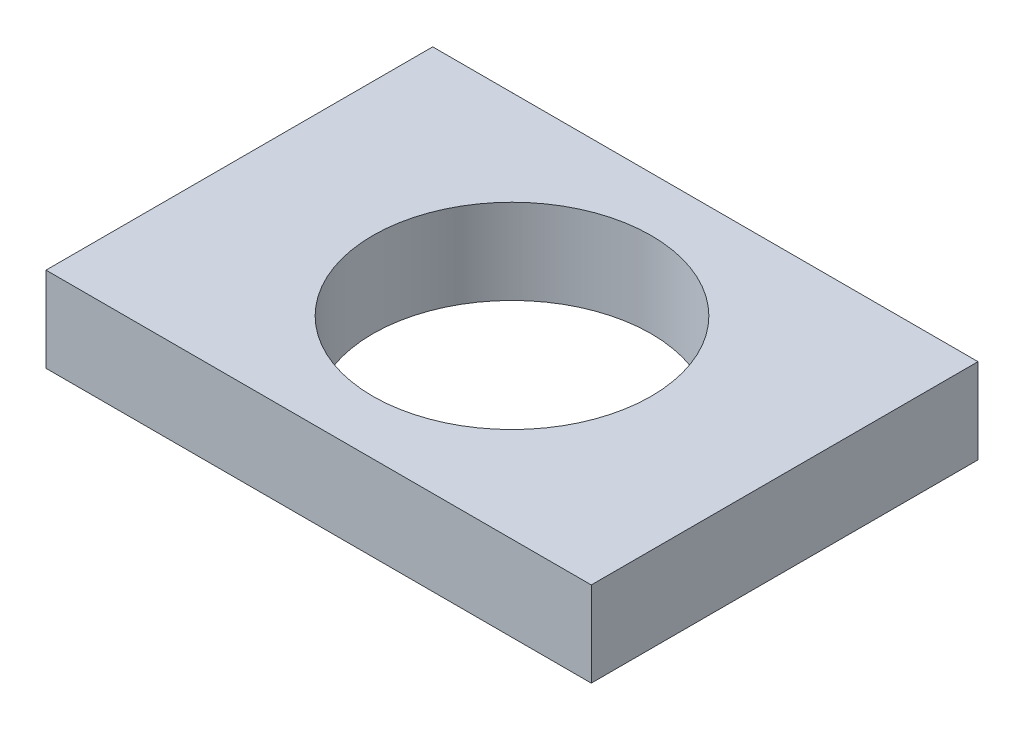
from build123d import *

# Parameters (mm, degrees)
SKETCH1_W           = 21.15
SKETCH1_H           = 15
BOSS_EXTRUDE2_DEPTH = 3.3
SKETCH3_R           = 5.4
CUT_EXTRUDE2_DEPTH  = 3.45


with BuildPart() as part:
    # Sketch1 → Boss-Extrude2 (new body)
    with BuildSketch(Plane(origin=(0, 0, 0), x_dir=(1, 0, 0), z_dir=(0, 1, 0))):
        Rectangle(SKETCH1_W, SKETCH1_H)
    extrude(amount=BOSS_EXTRUDE2_DEPTH)

    # Sketch3 → Cut-Extrude2 (cut)
    with BuildSketch(Plane(origin=(0, 3.3, 0), x_dir=(1, 0, 0), z_dir=(0, 1, 0))):
        Circle(SKETCH3_R)
    extrude(amount=-CUT_EXTRUDE2_DEPTH, mode=Mode.SUBTRACT)


solid = part.part
